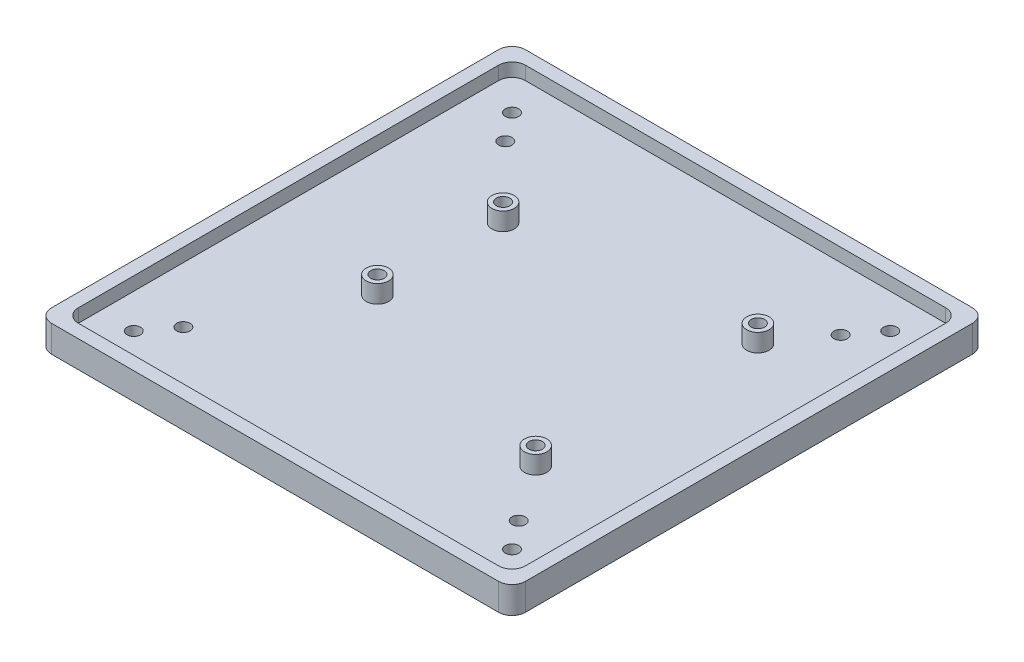
from build123d import *

# Parameters (mm, degrees)
SKETCH1_W                = 145.96883028
SKETCH1_H                = 100
SKETCH1_R                = 1.5
BOSS_EXTRUDE1_DEPTH      = 3
SKETCH4_R                = 2.5
SKETCH4_R_2              = 1.5
BOSS_EXTRUDE4_DEPTH      = 4
SKETCH5_W                = 45.97
SKETCH5_H                = 134.813317764
CUT_EXTRUDE3_DEPTH       = 10
SKETCH7_W                = 105.99883028
SKETCH7_H                = 106
SKETCH7_W_2              = 99.99883028
SKETCH7_H_2              = 100
BOSS_EXTRUDE5_DEPTH      = 3
BOSS_EXTRUDE5_DEPTH_BACK = 3
FILLET1_R                = 3
SKETCH8_R                = 1.5
CUT_EXTRUDE4_DEPTH       = 10
SKETCH9_R                = 1.5
CUT_EXTRUDE5_DEPTH       = 94.303972821


with BuildPart() as part:
    # Sketch1 → Boss-Extrude1 (new body)
    with BuildSketch(Plane(origin=(0, 0, 0), x_dir=(1, 0, 0), z_dir=(0, 1, 0))):
        with Locations((0, 1)):
            Rectangle(SKETCH1_W, SKETCH1_H)
        with Locations(Location((52.98441514, 26, 0), (0, 0, 270))):
            Circle(SKETCH1_R, mode=Mode.SUBTRACT)
        with Locations(Location((0.98441514, 21, 0), (0, 0, 270))):
            Circle(SKETCH1_R, mode=Mode.SUBTRACT)
        with Locations(Location((0.98441514, -7.1, 0), (0, 0, 270))):
            Circle(SKETCH1_R, mode=Mode.SUBTRACT)
        with Locations(Location((51.78441514, -22.5, 0), (0, 0, 270))):
            Circle(SKETCH1_R, mode=Mode.SUBTRACT)
        with Locations(Location((-66.5, 14.15, 0), (0, 0, 270))):
            Circle(SKETCH1_R, mode=Mode.SUBTRACT)
        with Locations(Location((-35.9, 14.15, 0), (0, 0, 270))):
            Circle(SKETCH1_R, mode=Mode.SUBTRACT)
        with Locations(Location((-66.5, -12.15, 0), (0, 0, 270))):
            Circle(SKETCH1_R, mode=Mode.SUBTRACT)
        with Locations(Location((-36.1, -12.15, 0), (0, 0, 270))):
            Circle(SKETCH1_R, mode=Mode.SUBTRACT)
        with Locations(Location((-65.48441514, 38.5, 0), (0, 0, 270))):
            Circle(SKETCH1_R, mode=Mode.SUBTRACT)
        with Locations(Location((-65.48441514, -36.5, 0), (0, 0, 270))):
            Circle(SKETCH1_R, mode=Mode.SUBTRACT)
    extrude(amount=BOSS_EXTRUDE1_DEPTH)

    # Sketch4 → Boss-Extrude4 (add)
    with BuildSketch(Plane(origin=(0, 3, 0), x_dir=(1, 0, 0), z_dir=(0, 1, 0))):
        with Locations(Location((51.78441514, -22.5, 0), (0, 0, 270))):
            Circle(SKETCH4_R)
        with Locations(Location((51.78441514, -22.5, 0), (0, 0, 270))):
            Circle(SKETCH4_R_2, mode=Mode.SUBTRACT)
        with Locations(Location((52.98441514, 26, 0), (0, 0, 270))):
            Circle(SKETCH4_R)
        with Locations(Location((52.98441514, 26, 0), (0, 0, 270))):
            Circle(SKETCH4_R_2, mode=Mode.SUBTRACT)
        with Locations(Location((0.98441514, -7.1, 0), (0, 0, 270))):
            Circle(SKETCH4_R)
        with Locations(Location((0.98441514, -7.1, 0), (0, 0, 270))):
            Circle(SKETCH4_R_2, mode=Mode.SUBTRACT)
        with Locations(Location((0.98441514, 21, 0), (0, 0, 270))):
            Circle(SKETCH4_R)
        with Locations(Location((0.98441514, 21, 0), (0, 0, 270))):
            Circle(SKETCH4_R_2, mode=Mode.SUBTRACT)
        with Locations(Location((-35.9, 14.15, 0), (0, 0, 270))):
            Circle(SKETCH4_R)
        with Locations(Location((-35.9, 14.15, 0), (0, 0, 270))):
            Circle(SKETCH4_R_2, mode=Mode.SUBTRACT)
        with Locations(Location((-36.1, -12.15, 0), (0, 0, 270))):
            Circle(SKETCH4_R)
        with Locations(Location((-36.1, -12.15, 0), (0, 0, 270))):
            Circle(SKETCH4_R_2, mode=Mode.SUBTRACT)
        with Locations(Location((-66.5, -12.15, 0), (0, 0, 270))):
            Circle(SKETCH4_R)
        with Locations(Location((-66.5, -12.15, 0), (0, 0, 270))):
            Circle(SKETCH4_R_2, mode=Mode.SUBTRACT)
        with Locations(Location((-66.5, 14.15, 0), (0, 0, 270))):
            Circle(SKETCH4_R)
        with Locations(Location((-66.5, 14.15, 0), (0, 0, 270))):
            Circle(SKETCH4_R_2, mode=Mode.SUBTRACT)
    extrude(amount=BOSS_EXTRUDE4_DEPTH)

    # Sketch5 → Cut-Extrude3 (cut)
    with BuildSketch(Plane(origin=(0, 3, 0), x_dir=(1, 0, 0), z_dir=(0, 1, 0))):
        with Locations((-49.99941514, -5.501317008)):
            Rectangle(SKETCH5_W, SKETCH5_H)
    extrude(amount=-CUT_EXTRUDE3_DEPTH, mode=Mode.SUBTRACT)


with BuildPart() as cut_extrude3_kept_piece:
    # of the separate pieces the step leaves, the one the design keeps (cut_extrude3_pieces_kept)
    add(part.part.solids().sort_by_distance((-27.01441514, 0, -51))[0])

    # Sketch7 → Boss-Extrude5 (add, two sides)
    with BuildSketch(Plane(origin=(0, 3, 0), x_dir=(1, 0, 0), z_dir=(0, 1, 0))) as boss_extrude5_sk:
        with Locations((22.985, 1)):
            Rectangle(SKETCH7_W, SKETCH7_H)
        with Locations((22.985, 1)):
            Rectangle(SKETCH7_W_2, SKETCH7_H_2, mode=Mode.SUBTRACT)
    extrude(amount=BOSS_EXTRUDE5_DEPTH)
    extrude(boss_extrude5_sk.sketch, amount=-BOSS_EXTRUDE5_DEPTH_BACK)

    # Fillet1
    fillet1_edges = [cut_extrude3_kept_piece.edges().sort_by_distance(p)[0] for p in [
        (-30.01441514, 3, -54),
        (75.98441514, 3, -54),
        (75.98441514, 3, 52),
        (-30.01441514, 3, 52),
        (72.98441514, 4.5, -51),
        (72.98441514, 4.5, 49),
        (-27.01441514, 4.5, 49),
        (-27.01441514, 4.5, -51),
    ]]
    fillet(fillet1_edges, radius=FILLET1_R)

    # Sketch8 → Cut-Extrude4 (cut)
    with BuildSketch(Plane(origin=(0, 3, 0), x_dir=(1, 0, 0), z_dir=(0, 1, 0))):
        with Locations(Location((65.28441514, -41.3, 0), (0, 0, 270))):
            Circle(SKETCH8_R)
        with Locations(Location((65.28441514, 43.3, 0), (0, 0, 270))):
            Circle(SKETCH8_R)
        with Locations(Location((-19.31441514, -41.3, 0), (0, 0, 270))):
            Circle(SKETCH8_R)
        with Locations(Location((-19.31441514, 43.3, 0), (0, 0, 270))):
            Circle(SKETCH8_R)
    extrude(amount=-CUT_EXTRUDE4_DEPTH, mode=Mode.SUBTRACT)

    # Sketch9 → Cut-Extrude5 (cut, through all)
    with BuildSketch(Plane(origin=(0, 3, 0), x_dir=(1, 0, 0), z_dir=(0, 1, 0))):
        with Locations(Location((-14.51441514, -35, 0), (0, 0, 270))):
            Circle(SKETCH9_R)
        with Locations(Location((-14.51441514, 37, 0), (0, 0, 270))):
            Circle(SKETCH9_R)
        with Locations(Location((60.48441514, -35, 0), (0, 0, 270))):
            Circle(SKETCH9_R)
        with Locations(Location((60.48441514, 37, 0), (0, 0, 270))):
            Circle(SKETCH9_R)
    extrude(amount=-CUT_EXTRUDE5_DEPTH, mode=Mode.SUBTRACT)


solid = cut_extrude3_kept_piece.part
